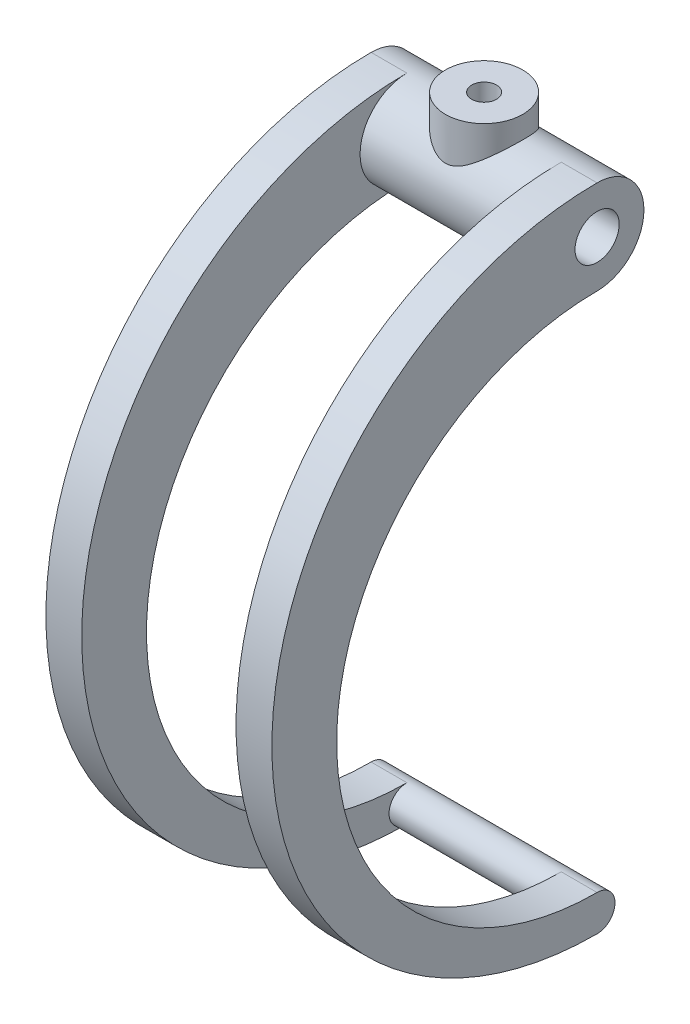
from build123d import *

# Parameters (mm, degrees)
SKETCH2_R           = 13.49375
SKETCH2_R_2         = 6.3627
BOSS_EXTRUDE1_DEPTH = 32.54375
BOSS_EXTRUDE2_REACH = 35.337
SKETCH3_R           = 11.1125
SKETCH3_R_2         = 3.571875
CUT_EXTRUDE1_REACH  = 35.338
SKETCH3_2_R         = 3.571875
SKETCH4_R           = 13.49375
SKETCH4_R_2         = 6.3627
SKETCH4_R_3         = 5.159375
BOSS_EXTRUDE3_DEPTH = 10.31875
BOSS_EXTRUDE4_REACH = 67.088
SKETCH4_3_R         = 5.159375


with BuildPart() as part:
    # Sketch2 → Boss-Extrude1 (new body, symmetric)
    with BuildSketch(Plane(origin=(0, 0, 0), x_dir=(0, 0, -1), z_dir=(1, 0, 0))):
        Circle(SKETCH2_R)
        Circle(SKETCH2_R_2, mode=Mode.SUBTRACT)
    extrude(amount=BOSS_EXTRUDE1_DEPTH, both=True)

    # Sketch3 → Boss-Extrude2 (add, up to next)
    with BuildSketch(Plane(origin=(0, 19.84375, 0), x_dir=(1, 0, 0), z_dir=(0, 1, 0)), mode=Mode.PRIVATE) as boss_extrude2_sk1:
        Circle(SKETCH3_R)
        Circle(SKETCH3_R_2, mode=Mode.SUBTRACT)
    boss_extrude2_tool1 = extrude(boss_extrude2_sk1.sketch, amount=-BOSS_EXTRUDE2_REACH, mode=Mode.PRIVATE) - part.part
    add(boss_extrude2_tool1.solids().sort_by_distance((-10.798191, 19.84375, 0))[0])

    # Sketch3_2 → Cut-Extrude1 (cut, up to next)
    with BuildSketch(Plane(origin=(0, 19.84375, 0), x_dir=(1, 0, 0), z_dir=(0, 1, 0)), mode=Mode.PRIVATE) as cut_extrude1_sk1:
        Circle(SKETCH3_2_R)
    cut_extrude1_tool1 = extrude(cut_extrude1_sk1.sketch, amount=-CUT_EXTRUDE1_REACH, mode=Mode.PRIVATE) & part.part
    add(cut_extrude1_tool1.solids().sort_by_distance((0, 19.84375, 0))[0], mode=Mode.SUBTRACT)

    # Sketch4 → Boss-Extrude3 (add)
    with BuildSketch(Plane(origin=(32.54375, 0, 0), x_dir=(0, 0, -1), z_dir=(1, 0, 0))):
        with BuildLine():
            ThreePointArc((0, -13.49375), (-13.49375, 0), (0, 13.49375))
            ThreePointArc((0, 13.49375), (-93.6625, -80.16875), (0, -173.83125))
            ThreePointArc((0, -173.83125), (-5.159375, -168.671875), (0, -163.5125))
            ThreePointArc((0, -163.5125), (-75.009375, -88.503125), (0, -13.49375))
        make_face()
        Circle(SKETCH4_R)
        Circle(SKETCH4_R_2, mode=Mode.SUBTRACT)
        with Locations((0, -168.671875)):
            Circle(SKETCH4_R_3)
    boss_extrude3 = extrude(amount=-BOSS_EXTRUDE3_DEPTH)

    # Mirror1: Boss-Extrude3 across plane
    add(boss_extrude3.mirror(Plane(origin=(0, 0, 0), x_dir=(0, 0, 1), z_dir=(1, 0, 0))))

    # Sketch4_3 → Boss-Extrude4 (add, up to next)
    with BuildSketch(Plane(origin=(32.54375, 0, 0), x_dir=(0, 0, -1), z_dir=(1, 0, 0)), mode=Mode.PRIVATE) as boss_extrude4_sk1:
        with Locations((0, -168.671875)):
            Circle(SKETCH4_3_R)
    boss_extrude4_tool1 = extrude(boss_extrude4_sk1.sketch, amount=-BOSS_EXTRUDE4_REACH, mode=Mode.PRIVATE) - part.part
    add(boss_extrude4_tool1.solids().sort_by_distance((32.54375, -168.671875, 0))[0])


solid = part.part
